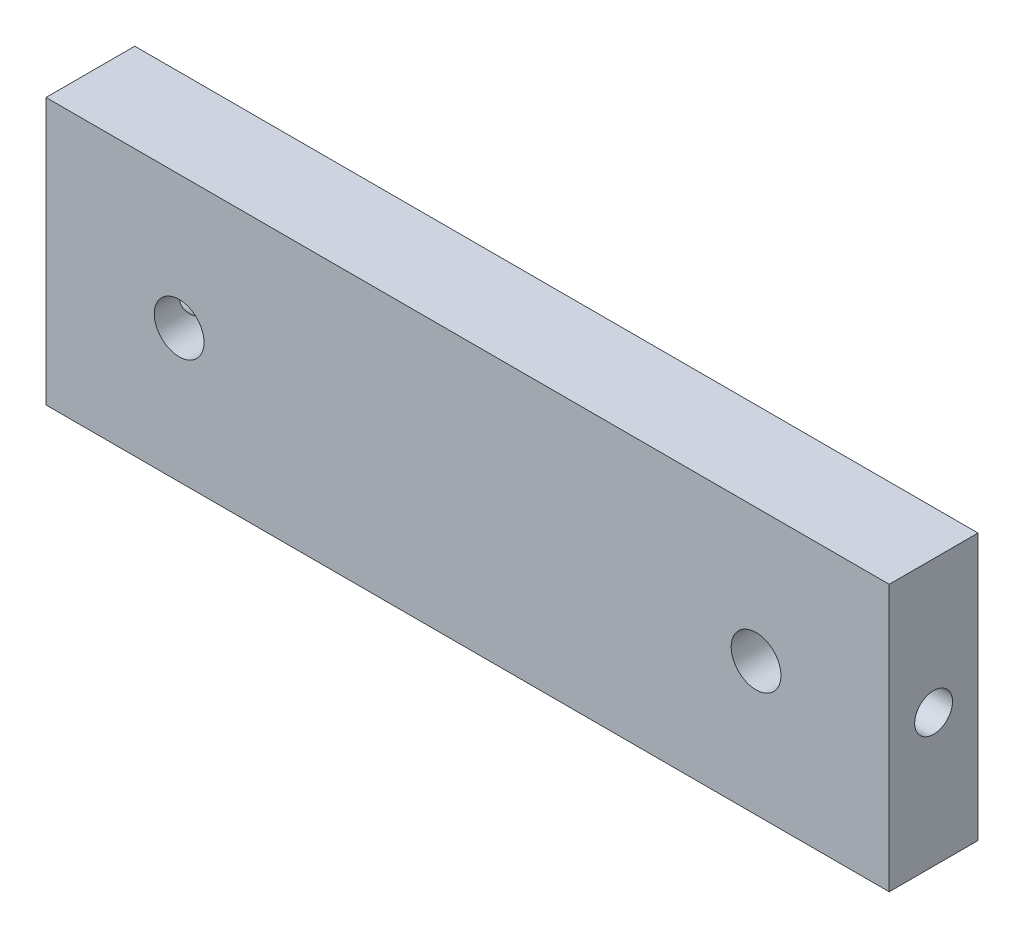
from build123d import *

# Parameters (mm, degrees)
SKETCH1_W                 = 60.3123
SKETCH1_H                 = 19.05
EXTRUDE1_DEPTH            = 6.35
SKETCH2_R                 = 1.778
CUT_EXTRUDE1_DEPTH        = 7.35
F_6_32_TAPPED_HOLE1_D     = 2.7051
F_6_32_TAPPED_HOLE1_DEPTH = 9.525
F_6_32_TAPPED_HOLE1_TIP   = 0.81269403
F_6_32_TAPPED_HOLE2_D     = 2.7051
F_6_32_TAPPED_HOLE2_DEPTH = 9.525
F_6_32_TAPPED_HOLE2_TIP   = 0.81269403


with BuildPart() as part:
    # Sketch1 → Extrude1 (new body)
    with BuildSketch(Plane.XY):
        with Locations((30.15615, 9.525)):
            Rectangle(SKETCH1_W, SKETCH1_H)
    extrude(amount=EXTRUDE1_DEPTH)

    # Sketch2 → Cut-Extrude1 (cut, through all)
    with BuildSketch(Plane.XY.offset(6.35)):
        with Locations((9.525, 9.525)):
            Circle(SKETCH2_R)
        with Locations((50.7873, 9.525)):
            Circle(SKETCH2_R)
    extrude(amount=-CUT_EXTRUDE1_DEPTH, mode=Mode.SUBTRACT)

    # #6-32 Tapped Hole1
    with Locations(Plane.ZY):
        with Locations((3.175, 9.525)):
            Hole(F_6_32_TAPPED_HOLE1_D / 2, depth=F_6_32_TAPPED_HOLE1_DEPTH)
            with Locations((0, 0, -(F_6_32_TAPPED_HOLE1_DEPTH + F_6_32_TAPPED_HOLE1_TIP / 2))):  # 118° drill point
                Cone(0, F_6_32_TAPPED_HOLE1_D / 2, F_6_32_TAPPED_HOLE1_TIP, mode=Mode.SUBTRACT)

    # #6-32 Tapped Hole2
    with Locations(Plane(origin=(60.3123, 0, 0), x_dir=(0, 0, -1), z_dir=(1, 0, 0))):
        with Locations((-3.175, 9.525)):
            Hole(F_6_32_TAPPED_HOLE2_D / 2, depth=F_6_32_TAPPED_HOLE2_DEPTH)
            with Locations((0, 0, -(F_6_32_TAPPED_HOLE2_DEPTH + F_6_32_TAPPED_HOLE2_TIP / 2))):  # 118° drill point
                Cone(0, F_6_32_TAPPED_HOLE2_D / 2, F_6_32_TAPPED_HOLE2_TIP, mode=Mode.SUBTRACT)


solid = part.part
